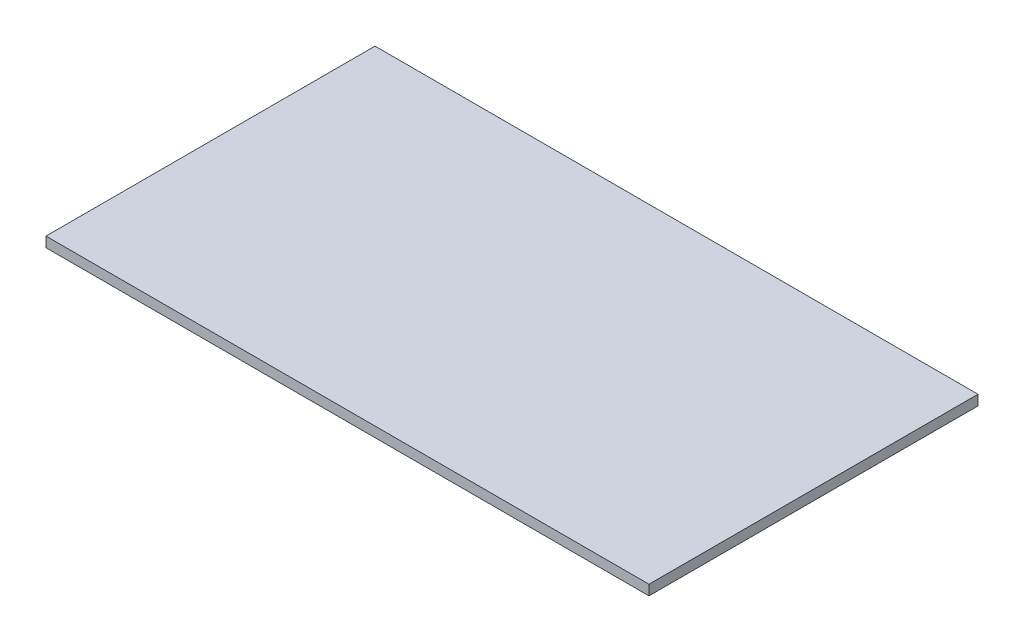
from build123d import *

# Parameters (mm, degrees)
SKETCH1_W           = 119.2
SKETCH1_H           = 65.04
BOSS_EXTRUDE1_DEPTH = 2


with BuildPart() as part:
    # Sketch1 → Boss-Extrude1 (new body)
    with BuildSketch(Plane(origin=(0, 0, 0), x_dir=(1, 0, 0), z_dir=(0, 1, 0))):
        Rectangle(SKETCH1_W, SKETCH1_H)
    extrude(amount=BOSS_EXTRUDE1_DEPTH)


solid = part.part
